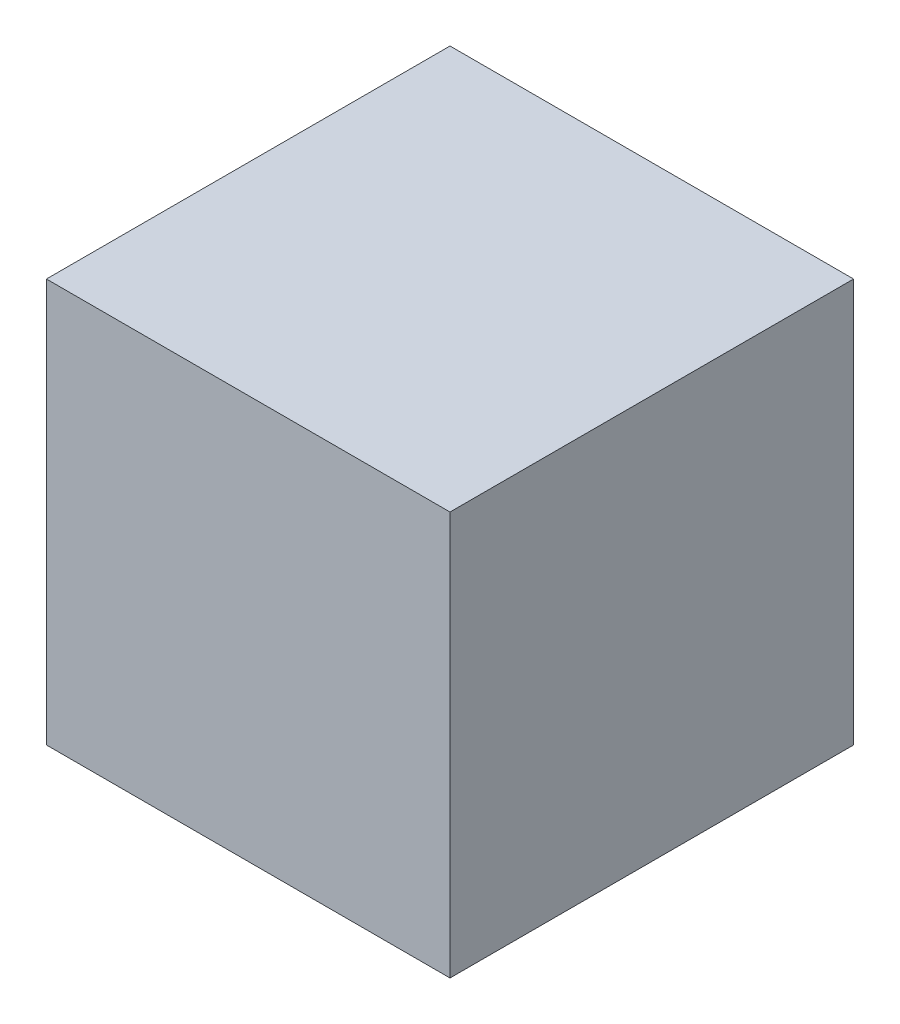
from build123d import *

# Parameters (mm, degrees)
SKETCH_1_W      = 600
SKETCH_1_H      = 600
EXTRUDE_1_DEPTH = 600


with BuildPart() as part:
    # 草图1 → 凸台-拉伸1 (new body)
    with BuildSketch(Plane.XY):
        Rectangle(SKETCH_1_W, SKETCH_1_H)
    extrude(amount=EXTRUDE_1_DEPTH)


solid = part.part
